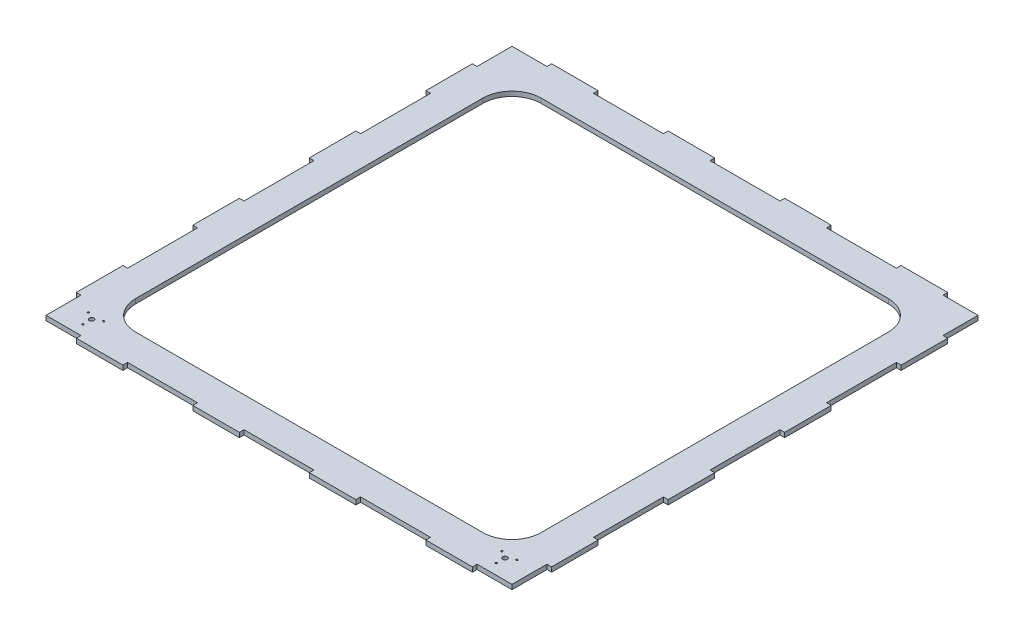
from build123d import *

# Parameters (mm, degrees)
BOSS_EXTRUDE1_DEPTH = 8
CUT_EXTRUDE1_DEPTH  = 10
SKETCH3_R           = 4
SKETCH3_R_2         = 1.5
CUT_EXTRUDE2_DEPTH  = 10


with BuildPart() as part:
    # Sketch1 → Boss-Extrude1 (new body)
    with BuildSketch(Plane(origin=(0, 0, 0), x_dir=(1, 0, 0), z_dir=(0, 1, 0))):
        Polygon((340, 408), (260, 408), (260, 400), (140, 400), (140, 408), (60, 408), (60, 400), (-60, 400), (-60, 408), (-140, 408), (-140, 400), (-260, 400), (-260, 408), (-340, 408), (-340, 400), (-400, 400), (-400, 340), (-408, 340), (-408, 260), (-400, 260), (-400, 140), (-408, 140), (-408, 60), (-400, 60), (-400, -60), (-408, -60), (-408, -140), (-400, -140), (-400, -260), (-408, -260), (-408, -340), (-400, -340), (-400, -400), (-340, -400), (-340, -408), (-260, -408), (-260, -400), (-140, -400), (-140, -408), (-60, -408), (-60, -400), (60, -400), (60, -408), (140, -408), (140, -400), (260, -400), (260, -408), (340, -408), (340, -400), (400, -400), (400, -340), (408, -340), (408, -260), (400, -260), (400, -140), (408, -140), (408, -60), (400, -60), (400, 60), (408, 60), (408, 140), (400, 140), (400, 260), (408, 260), (408, 340), (400, 340), (400, 400), (340, 400), align=None)
    extrude(amount=BOSS_EXTRUDE1_DEPTH)

    # Sketch2 → Cut-Extrude1 (cut)
    with BuildSketch(Plane(origin=(0, 8, 0), x_dir=(1, 0, 0), z_dir=(0, 1, 0))):
        with BuildLine():
            Line((-298, 348), (298, 348))
            ThreePointArc((298, 348), (333.355339059, 333.355339059), (348, 298))
            Line((348, 298), (348, -298))
            ThreePointArc((348, -298), (333.355339059, -333.355339059), (298, -348))
            Line((298, -348), (-298, -348))
            ThreePointArc((-298, -348), (-333.355339059, -333.355339059), (-348, -298))
            Line((-348, -298), (-348, 298))
            ThreePointArc((-348, 298), (-333.355339059, 333.355339059), (-298, 348))
        make_face()
    extrude(amount=-CUT_EXTRUDE1_DEPTH, mode=Mode.SUBTRACT)

    # Sketch3 → Cut-Extrude2 (cut)
    with BuildSketch(Plane(origin=(0, 8, 0), x_dir=(1, 0, 0), z_dir=(0, 1, 0))):
        with Locations((354.85, -366.85)):
            Circle(SKETCH3_R)
        with Locations((354.85, -381.85)):
            Circle(SKETCH3_R_2)
        with Locations((341.859618943, -359.35)):
            Circle(SKETCH3_R_2)
        with Locations((367.840381057, -359.35)):
            Circle(SKETCH3_R_2)
        with Locations((-367.840381057, -359.35)):
            Circle(SKETCH3_R_2)
        with Locations((-341.859618943, -359.35)):
            Circle(SKETCH3_R_2)
        with Locations((-354.85, -381.85)):
            Circle(SKETCH3_R_2)
        with Locations((-354.85, -366.85)):
            Circle(SKETCH3_R)
    extrude(amount=-CUT_EXTRUDE2_DEPTH, mode=Mode.SUBTRACT)


solid = part.part
